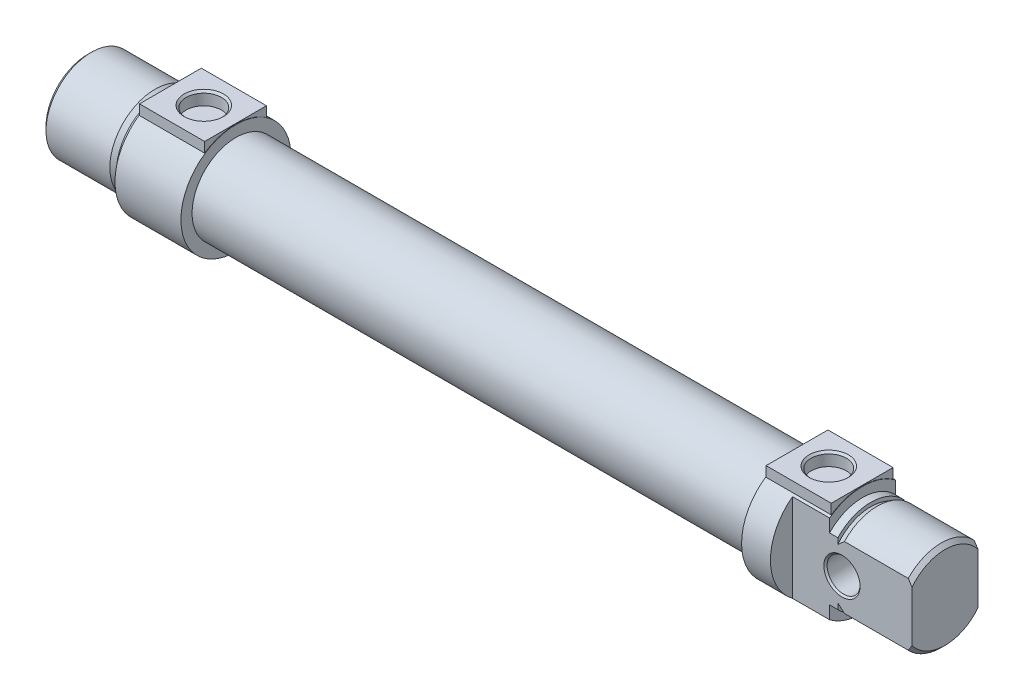
from build123d import *

# Parameters (mm, degrees)
SKETCH2_W               = 15.8
SKETCH2_H               = 15
BOSS_EXTRUDE1_DEPTH     = 6.75
SKETCH3_W               = 15.8
SKETCH3_H               = 15
BOSS_EXTRUDE2_DEPTH     = 6.75
CUT_EXTRUDE1_DEPTH      = 27
CUT_EXTRUDE1_DEPTH_BACK = 27
SKETCH8_R               = 4
CUT_EXTRUDE2_DEPTH      = 160.9
SKETCH9_W               = 106.666666667
SKETCH9_H               = 10


with BuildPart() as part:
    # Sketch1 → Revolve1 (revolve)
    with BuildSketch(Plane.XY, mode=Mode.PRIVATE) as revolve1_sk:
        Polygon((-20, 0), (-20, 10.08), (-19.08, 11), (-3.593486743, 11), (-2, 10.08), (-2, 11), (0, 11), (0, 13.35), (16, 13.35), (16, 10.65), (152, 10.65), (152, 13.35), (168, 13.35), (168, 11), (170, 11), (170, 10.08), (171.593486743, 11), (187.08, 11), (188, 10.08), (188, 0), align=None)
    revolve(revolve1_sk.sketch.rotate(Axis((188, 0, 0), (-1, 0, 0)), 270), axis=Axis((188, 0, 0), (-1, 0, 0)))  # turned: the seam where the file's is

    # Sketch2 → Boss-Extrude1 (add)
    with BuildSketch(Plane(origin=(0, 13.5, 0), x_dir=(-1, 0, 0), z_dir=(0, 1, 0))):
        with Locations((-8, 0)):
            Rectangle(SKETCH2_W, SKETCH2_H)
    extrude(amount=-BOSS_EXTRUDE1_DEPTH)

    # Sketch3 → Boss-Extrude2 (add)
    with BuildSketch(Plane(origin=(0, 13.5, 0), x_dir=(-1, 0, 0), z_dir=(0, 1, 0))):
        with Locations((-160, 0)):
            Rectangle(SKETCH3_W, SKETCH3_H)
    extrude(amount=-BOSS_EXTRUDE2_DEPTH)

    # Sketch4 → Cut-Revolve1 (revolve, cut)
    with BuildSketch(Plane.XY, mode=Mode.PRIVATE) as cut_revolve1_sk:
        Polygon((8.2, 13.6), (13.064, 13.6), (12.483, 13.019), (12.483, 10.357333333), (8.2, 10.357333333), align=None)
    revolve(cut_revolve1_sk.sketch.rotate(Axis((8.2, 10.357333333, 0), (0, 1, 0)), 270), axis=Axis((8.2, 10.357333333, 0), (0, 1, 0)), mode=Mode.SUBTRACT)  # turned: the seam where the file's is

    # Sketch5 → Cut-Revolve2 (revolve, cut)
    with BuildSketch(Plane.XY, mode=Mode.PRIVATE) as cut_revolve2_sk:
        Polygon((159.8, 13.6), (164.664, 13.6), (164.083, 13.019), (164.083, 10.357333333), (159.8, 10.357333333), align=None)
    revolve(cut_revolve2_sk.sketch.rotate(Axis((159.8, 10.357333333, 0), (0, 1, 0)), 270), axis=Axis((159.8, 10.357333333, 0), (0, 1, 0)), mode=Mode.SUBTRACT)  # turned: the seam where the file's is

    # Sketch6 → Cut-Extrude1 (cut, two sides)
    with BuildSketch(Plane(origin=(0, 0, 0), x_dir=(-1, 0, 0), z_dir=(0, 1, 0))) as cut_extrude1_sk:
        Polygon((-159, 30), (-205, 30), (-205, -30), (-159, -30), (-159, -8), (-189, -8), (-189, 8), (-159, 8), align=None)
    extrude(amount=CUT_EXTRUDE1_DEPTH, mode=Mode.SUBTRACT)
    extrude(cut_extrude1_sk.sketch, amount=-CUT_EXTRUDE1_DEPTH_BACK, mode=Mode.SUBTRACT)

    # Sketch7 → Cut-Revolve3 (revolve, cut)
    with BuildSketch(Plane(origin=(0, 0, 0), x_dir=(-1, 0, 0), z_dir=(0, 1, 0)), mode=Mode.PRIVATE) as cut_revolve3_sk:
        Polygon((-171, -8.1), (-175.5, -8.1), (-175, -7.6), (-175, 7.6), (-175.5, 8.1), (-171, 8.1), align=None)
    revolve(cut_revolve3_sk.sketch.rotate(Axis((171, 0, 8.1), (0, 0, -1)), 180), axis=Axis((171, 0, 8.1), (0, 0, -1)), mode=Mode.SUBTRACT)  # turned: the seam where the file's is

    # Sketch8 → Cut-Extrude2 (cut)
    with BuildSketch(Plane(origin=(-24, 0, 0), x_dir=(0, 0, -1), z_dir=(1, 0, 0))):
        Circle(SKETCH8_R)
    extrude(amount=CUT_EXTRUDE2_DEPTH, mode=Mode.SUBTRACT)

    # Sketch9 → Cut-Revolve4 (revolve, cut)
    with BuildSketch(Plane.XY, mode=Mode.PRIVATE) as cut_revolve4_sk:
        with Locations((83.666666667, 5)):
            Rectangle(SKETCH9_W, SKETCH9_H)
    revolve(cut_revolve4_sk.sketch.rotate(Axis((137, 0, 0), (-1, 0, 0)), 270), axis=Axis((137, 0, 0), (-1, 0, 0)), mode=Mode.SUBTRACT)  # turned: the seam where the file's is


solid = part.part
